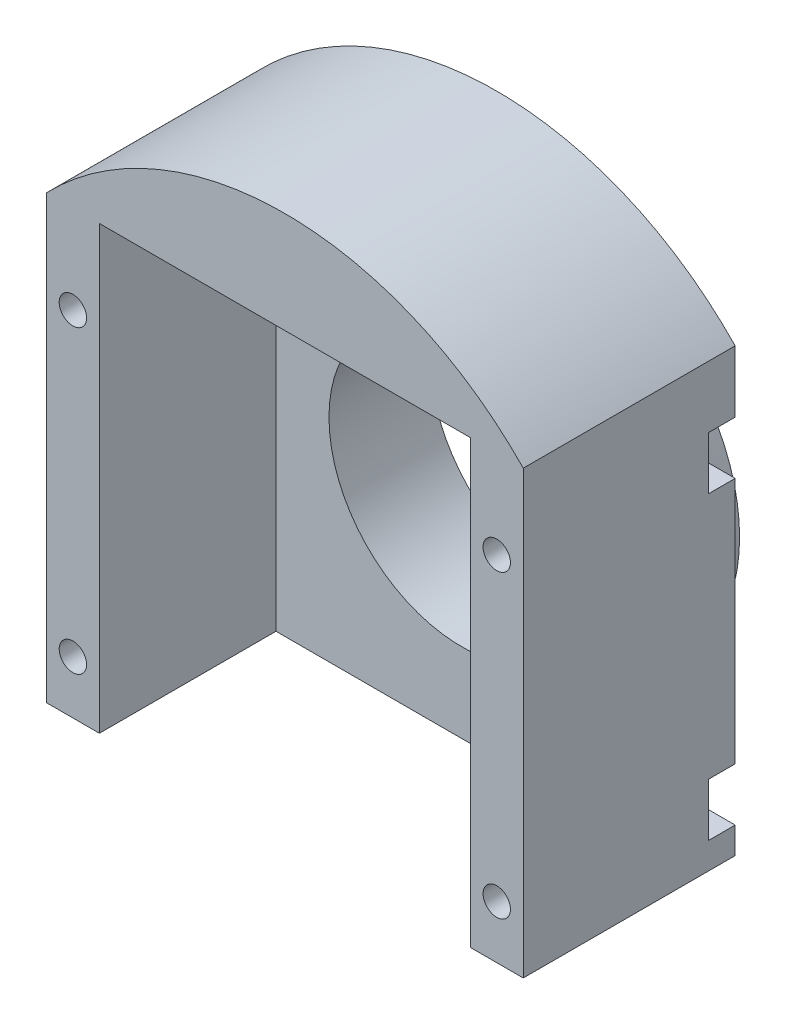
from build123d import *

# Parameters (mm, degrees)
SKETCH_1_W          = 54
SKETCH_1_H          = 50
EXTRUDE_1_DEPTH     = 24
SKETCH_2_R          = 1.55
CUT_EXTRUDE_1_DEPTH = 25
EXTRUDE_2_DEPTH     = 24
SKETCH_5_W          = 42
SKETCH_5_H          = 50
CUT_EXTRUDE_3_DEPTH = 20
CUT_EXTRUDE_4_DEPTH = 3
SKETCH_7_R          = 15
CUT_EXTRUDE_5_DEPTH = 25
SKETCH_11_R         = 20
SKETCH_11_R_2       = 15
EXTRUDE_3_DEPTH     = 7.5
SKETCH_12_R         = 21
SKETCH_12_R_2       = 20
EXTRUDE_4_DEPTH     = 0.5


with BuildPart() as part:
    # 草图1 → 凸台-拉伸1 (new body)
    with BuildSketch(Plane.XY):
        Rectangle(SKETCH_1_W, SKETCH_1_H)
    extrude(amount=EXTRUDE_1_DEPTH)

    # 草图2 → 切除-拉伸1 (cut, through all)
    with BuildSketch(Plane.XY.offset(24)):
        with Locations((-24, 15)):
            Circle(SKETCH_2_R)
        with Locations((24, 15)):
            Circle(SKETCH_2_R)
        with Locations((24, -19)):
            Circle(SKETCH_2_R)
        with Locations((-24, -19)):
            Circle(SKETCH_2_R)
    extrude(amount=-CUT_EXTRUDE_1_DEPTH, mode=Mode.SUBTRACT)

    # 草图3 → 凸台-拉伸2 (add)
    with BuildSketch(Plane.XY.offset(24)):
        with BuildLine():
            Line((-27, 25), (27, 25))
            ThreePointArc((27, 25), (0, 36.483329628), (-27, 25))
        make_face()
    extrude(amount=-EXTRUDE_2_DEPTH)

    # 草图5 → 切除-拉伸3 (cut)
    with BuildSketch(Plane.XY.offset(24)):
        Rectangle(SKETCH_5_W, SKETCH_5_H)
    extrude(amount=-CUT_EXTRUDE_3_DEPTH, mode=Mode.SUBTRACT)

    # 草图6 → 切除-拉伸4 (cut)
    with BuildSketch(Plane(origin=(0, 0, 0), x_dir=(-1, 0, 0), z_dir=(0, 0, -1))):
        with BuildLine():
            Line((-27, -16), (-24, -16))
            ThreePointArc((-24, -16), (-21, -19), (-24, -22))
            Line((-24, -22), (-27, -22))
            Line((-27, -22), (-27, -16))
        make_face()
        with BuildLine():
            Line((-27, 18), (-27, 12))
            Line((-27, 12), (-24, 12))
            ThreePointArc((-24, 12), (-21, 15), (-24, 18))
            Line((-24, 18), (-27, 18))
        make_face()
        with BuildLine():
            Line((27, -16), (24, -16))
            ThreePointArc((24, -16), (21, -19), (24, -22))
            Line((24, -22), (27, -22))
            Line((27, -22), (27, -16))
        make_face()
        with BuildLine():
            Line((27, 18), (24, 18))
            ThreePointArc((24, 18), (21, 15), (24, 12))
            Line((24, 12), (27, 12))
            Line((27, 12), (27, 18))
        make_face()
    extrude(amount=-CUT_EXTRUDE_4_DEPTH, mode=Mode.SUBTRACT)

    # 草图7 → 切除-拉伸5 (cut, through all)
    with BuildSketch(Plane(origin=(0, 0, 0), x_dir=(-1, 0, 0), z_dir=(0, 0, -1))):
        with Locations((0, -1)):
            Circle(SKETCH_7_R)
    extrude(amount=-CUT_EXTRUDE_5_DEPTH, mode=Mode.SUBTRACT)

    # 草图11 → 凸台-拉伸3 (add)
    with BuildSketch(Plane(origin=(0, 0, 0), x_dir=(-1, 0, 0), z_dir=(0, 0, -1))):
        with Locations((0, -1)):
            Circle(SKETCH_11_R)
        with Locations((0, -1)):
            Circle(SKETCH_11_R_2, mode=Mode.SUBTRACT)
    extrude(amount=EXTRUDE_3_DEPTH)

    # 草图12 → 凸台-拉伸4 (add)
    with BuildSketch(Plane(origin=(0, 0, 0), x_dir=(-1, 0, 0), z_dir=(0, 0, -1))):
        with Locations((0, -1)):
            Circle(SKETCH_12_R)
        with Locations((0, -1)):
            Circle(SKETCH_12_R_2, mode=Mode.SUBTRACT)
    extrude(amount=EXTRUDE_4_DEPTH)


solid = part.part
